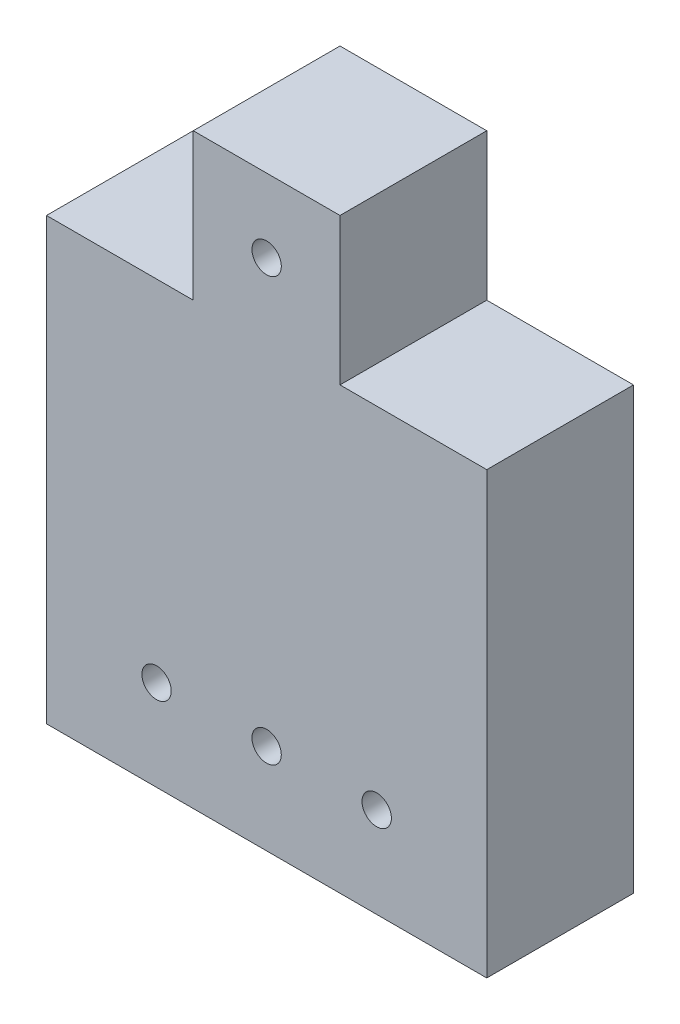
from build123d import *

# Parameters (mm, degrees)
SKETCH1_W           = 19.05
SKETCH1_H           = 25.4
BOSS_EXTRUDE1_DEPTH = 6.35
SKETCH2_W           = 6.35
SKETCH2_H           = 6.35
CUT_EXTRUDE1_DEPTH  = 7.35
SKETCH3_W           = 6.35
SKETCH3_H           = 6.35
CUT_EXTRUDE2_DEPTH  = 7.35
SKETCH4_R           = 0.635
CUT_EXTRUDE3_DEPTH  = 7.35
SKETCH5_R           = 0.635
CUT_EXTRUDE4_DEPTH  = 7.35


with BuildPart() as part:
    # Sketch1 → Boss-Extrude1 (new body)
    with BuildSketch(Plane.XY):
        with Locations((9.525, 12.7)):
            Rectangle(SKETCH1_W, SKETCH1_H)
    extrude(amount=BOSS_EXTRUDE1_DEPTH)

    # Sketch2 → Cut-Extrude1 (cut, through all)
    with BuildSketch(Plane(origin=(0, 0, 0), x_dir=(-1, 0, 0), z_dir=(0, 0, -1))):
        with Locations((-3.175, 22.225)):
            Rectangle(SKETCH2_W, SKETCH2_H)
    extrude(amount=-CUT_EXTRUDE1_DEPTH, mode=Mode.SUBTRACT)

    # Sketch3 → Cut-Extrude2 (cut, through all)
    with BuildSketch(Plane(origin=(0, 0, 0), x_dir=(-1, 0, 0), z_dir=(0, 0, -1))):
        with Locations((-15.875, 22.225)):
            Rectangle(SKETCH3_W, SKETCH3_H)
    extrude(amount=-CUT_EXTRUDE2_DEPTH, mode=Mode.SUBTRACT)

    # Sketch4 → Cut-Extrude3 (cut, through all)
    with BuildSketch(Plane(origin=(0, 0, 0), x_dir=(-1, 0, 0), z_dir=(0, 0, -1))):
        with Locations((-9.525, 22.225)):
            Circle(SKETCH4_R)
    extrude(amount=-CUT_EXTRUDE3_DEPTH, mode=Mode.SUBTRACT)

    # Sketch5 → Cut-Extrude4 (cut, through all)
    with BuildSketch(Plane.XY.offset(6.35)):
        with Locations((14.2875, 3.922050028)):
            Circle(SKETCH5_R)
        with Locations((9.525, 3.922050028)):
            Circle(SKETCH5_R)
        with Locations((4.7625, 3.922050028)):
            Circle(SKETCH5_R)
    extrude(amount=-CUT_EXTRUDE4_DEPTH, mode=Mode.SUBTRACT)


solid = part.part
